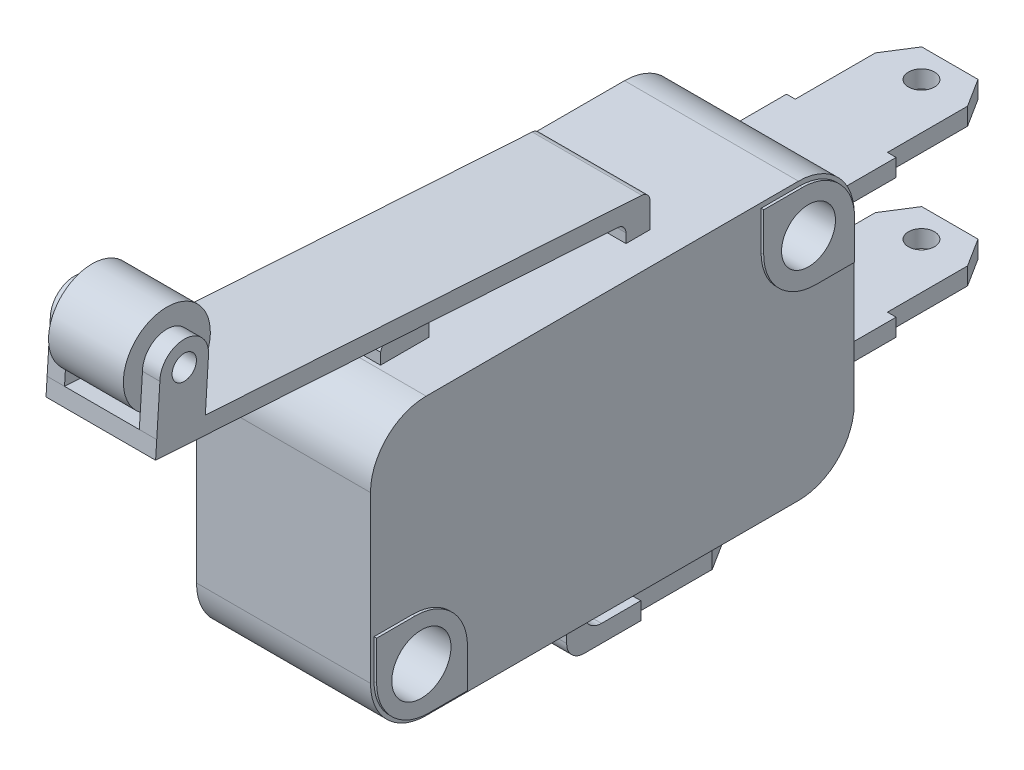
from build123d import *

# Parameters (mm, degrees)
BLOCOBASE_DEPTH           = 5
SKFIXACAO_R               = 1.7
SKFIXACAO_R_2             = 1.55
FIXACAO_DEPTH             = 5.15
RESSALTOFIXACAO_DEPTH     = 0.15
BOTAO_DEPTH               = 2.15
SKETCH5_W                 = 6.3
SKETCH5_H                 = 1
BASECONECTORNONC_DEPTH    = 10.5
SKDESENHOCONECTORNONC_R   = 0.75
DESENHOCONECTORNONC_DEPTH = 20.5
BASECONECTORCOM_DEPTH     = 3.15
SKDESENHOCONECTORCOM_R    = 0.75
DESENHOCONECTORCOM_DEPTH  = 1
BASECONTATO_DEPTH         = 3.15
SKAPOIOROLO_R             = 0.7
APOIOROLO_DEPTH           = 1
SKROLO_R                  = 2.5
ROLO_DEPTH                = 4.3


with BuildPart() as part:
    # skBlocoBase → BlocoBase (new body, symmetric)
    with BuildSketch(Plane(origin=(0, 0, 0), x_dir=(0, 0, -1), z_dir=(1, 0, 0))):
        with BuildLine():
            Line((-10.7, 7.95), (10.7, 7.95))
            ThreePointArc((10.7, 7.95), (12.9627417, 7.0127417), (13.9, 4.75))
            Line((13.9, 4.75), (13.9, -4.75))
            ThreePointArc((13.9, -4.75), (12.9627417, -7.0127417), (10.7, -7.95))
            Line((10.7, -7.95), (-10.7, -7.95))
            ThreePointArc((-10.7, -7.95), (-12.9627417, -7.0127417), (-13.9, -4.75))
            Line((-13.9, -4.75), (-13.9, 4.75))
            ThreePointArc((-13.9, 4.75), (-12.9627417, 7.0127417), (-10.7, 7.95))
        make_face()
    extrude(amount=BLOCOBASE_DEPTH, both=True)

    # skFixacao → Fixacao (cut, symmetric)
    with BuildSketch(Plane(origin=(0, 0, 0), x_dir=(0, 0, -1), z_dir=(1, 0, 0))):
        with Locations((-11.125, -5.1)):
            Circle(SKFIXACAO_R)
        with Locations((11.125, 5.1)):
            Circle(SKFIXACAO_R_2)
    extrude(amount=FIXACAO_DEPTH, both=True, mode=Mode.SUBTRACT)

    # skRessaltoFixacao → RessaltoFixacao (add)
    with BuildSketch(Plane(origin=(5, 0, 0), x_dir=(0, 0, -1), z_dir=(1, 0, 0))):
        with BuildLine():
            ThreePointArc((-8.475, -5.525), (-9.353679656, -3.403679656), (-11.475, -2.525))
            Line((-11.475, -2.525), (-13.7, -2.525))
            Line((-13.7, -2.525), (-13.7, -4.75))
            ThreePointArc((-13.7, -4.75), (-12.821320344, -6.871320344), (-10.7, -7.75))
            Line((-10.7, -7.75), (-8.475, -7.75))
            Line((-8.475, -7.75), (-8.475, -5.525))
        make_face()
        with BuildLine():
            ThreePointArc((-9.789845005, -6.152312282), (-10.474438165, -6.670595205), (-11.325, -6.788194302))
            ThreePointArc((-11.325, -6.788194302), (-11.775561835, -3.529404795), (-9.789845005, -6.152312282))
        make_face(mode=Mode.SUBTRACT)
        with BuildLine():
            ThreePointArc((13.775, 4.675), (12.896320344, 6.796320344), (10.775, 7.675))
            Line((10.775, 7.675), (8.55, 7.675))
            Line((8.55, 7.675), (8.55, 5.45))
            ThreePointArc((8.55, 5.45), (9.428679656, 3.328679656), (11.55, 2.45))
            Line((11.55, 2.45), (13.775, 2.45))
            Line((13.775, 2.45), (13.775, 4.675))
        make_face()
        with BuildLine():
            ThreePointArc((12.353274612, 4.1545681), (11.71815932, 3.667986725), (10.925, 3.562957385))
            ThreePointArc((10.925, 3.562957385), (10.53184068, 6.532013275), (12.353274612, 4.1545681))
        make_face(mode=Mode.SUBTRACT)
    ressaltofixacao = extrude(amount=RESSALTOFIXACAO_DEPTH)

    # MirrorRessaltoFixacao: RessaltoFixacao across plane
    add(ressaltofixacao.mirror(Plane(origin=(0, 0, 0), x_dir=(0, 0, 1), z_dir=(1, 0, 0))))

    # skBotao → Botao (add, symmetric)
    with BuildSketch(Plane(origin=(0, 0, 0), x_dir=(0, 0, -1), z_dir=(1, 0, 0))):
        with BuildLine():
            Line((-10.475, 7.95), (-10.475, 8.6))
            ThreePointArc((-10.475, 8.6), (-9.075, 9.6), (-7.675, 8.6))
            Line((-7.675, 8.6), (-7.675, 7.95))
            Line((-7.675, 7.95), (-10.475, 7.95))
        make_face()
    extrude(amount=BOTAO_DEPTH, both=True)

    # Sketch5 → BaseConectorNONC (add)
    with BuildSketch(Plane(origin=(0, 0, -13.9), x_dir=(-1, 0, 0), z_dir=(0, 0, -1))):
        with Locations((0, -3.975)):
            Rectangle(SKETCH5_W, SKETCH5_H)
        with Locations((0, 3.975)):
            Rectangle(SKETCH5_W, SKETCH5_H)
    extrude(amount=BASECONECTORNONC_DEPTH)

    # skDesenhoConectorNONC → DesenhoConectorNONC (cut)
    with BuildSketch(Plane.XZ.offset(4.475)):
        Polygon((2.65, -22.767142952), (1.616967042, -24.4), (3.15, -24.4), (3.15, -18.161236833), (2.65, -18.161236833), align=None)
        Polygon((-3.15, -24.4), (-1.616967042, -24.4), (-2.65, -22.767142952), (-2.65, -18.161236833), (-3.15, -18.161236833), align=None)
        with Locations((0, -22.767142952)):
            Circle(SKDESENHOCONECTORNONC_R)
    extrude(amount=-DESENHOCONECTORNONC_DEPTH, mode=Mode.SUBTRACT)

    # skBaseConectorCOM → BaseConectorCOM (add, symmetric)
    with BuildSketch(Plane(origin=(0, 0, 0), x_dir=(0, 0, -1), z_dir=(1, 0, 0))):
        with BuildLine():
            Line((9.725, -11.25), (0.225, -11.25))
            ThreePointArc((0.225, -11.25), (-0.482106781, -10.957106781), (-0.775, -10.25))
            Line((-0.775, -10.25), (-0.775, -7.95))
            Line((-0.775, -7.95), (0.225, -7.95))
            Line((0.225, -7.95), (0.225, -9.25))
            ThreePointArc((0.225, -9.25), (0.517893219, -9.957106781), (1.225, -10.25))
            Line((1.225, -10.25), (9.725, -10.25))
            Line((9.725, -10.25), (9.725, -11.25))
        make_face()
    extrude(amount=BASECONECTORCOM_DEPTH, both=True)

    # skDesenhoConectorCOM → DesenhoConectorCOM (cut)
    with BuildSketch(Plane.XZ.offset(11.25)):
        Polygon((2.65, -8.092142952), (1.616967042, -9.725), (3.15, -9.725), (3.15, -3.486236833), (2.65, -3.486236833), align=None)
        Polygon((-3.15, -9.725), (-1.616967042, -9.725), (-2.65, -8.092142952), (-2.65, -3.486236833), (-3.15, -3.486236833), align=None)
        with Locations((0, -8.092142952)):
            Circle(SKDESENHOCONECTORCOM_R)
    extrude(amount=-DESENHOCONECTORCOM_DEPTH, mode=Mode.SUBTRACT)

    # skBaseContato → BaseContato (add, symmetric)
    with BuildSketch(Plane(origin=(0, 0, 0), x_dir=(0, 0, -1), z_dir=(1, 0, 0))):
        with BuildLine():
            Line((2.63302332, 7.95), (2.63302332, 8.486635004))
            ThreePointArc((2.63302332, 8.486635004), (2.497665983, 8.828739854), (2.164880406, 8.985619098))
            Line((2.164880406, 8.985619098), (-24.4, 10.681624431))
            Line((-24.4, 10.681624431), (-24.336285828, 11.679592619))
            Line((-24.336285828, 11.679592619), (3.545575005, 9.899506131))
            ThreePointArc((3.545575005, 9.899506131), (3.878360582, 9.742626887), (4.013717919, 9.400522037))
            Line((4.013717919, 9.400522037), (4.013717919, 7.95))
            Line((4.013717919, 7.95), (2.63302332, 7.95))
        make_face()
    extrude(amount=BASECONTATO_DEPTH, both=True)

    # skApoioRolo → ApoioRolo (add)
    with BuildSketch(Plane(origin=(3.15, 0, 0), x_dir=(0, 0, -1), z_dir=(1, 0, 0))):
        with BuildLine():
            ThreePointArc((-21.354211514, 14.486814776), (-22.754211514, 15.886814776), (-24.154211514, 14.486814776))
            Line((-24.154211514, 14.486814776), (-24.336285828, 11.679592619))
            Line((-24.336285828, 11.679592619), (-22.939130364, 11.590392778))
            Line((-22.939130364, 11.590392778), (-21.541974901, 11.501192936))
            Line((-21.541974901, 11.501192936), (-21.365242034, 14.3114187))
            Line((-21.365242034, 14.3114187), (-21.354211514, 14.486814776))
        make_face()
        with Locations((-22.754211514, 14.486814776)):
            Circle(SKAPOIOROLO_R, mode=Mode.SUBTRACT)
    apoiorolo = extrude(amount=-APOIOROLO_DEPTH)

    # MirrorApoioRolo: ApoioRolo across plane
    add(apoiorolo.mirror(Plane(origin=(0, 0, 0), x_dir=(0, 0, 1), z_dir=(1, 0, 0))))

    # skRolo → Rolo (add)
    with BuildSketch(Plane.ZY.offset(-2.15)):
        with Locations((22.754211514, 14.486814776)):
            Circle(SKROLO_R)
    extrude(amount=ROLO_DEPTH)


solid = part.part
